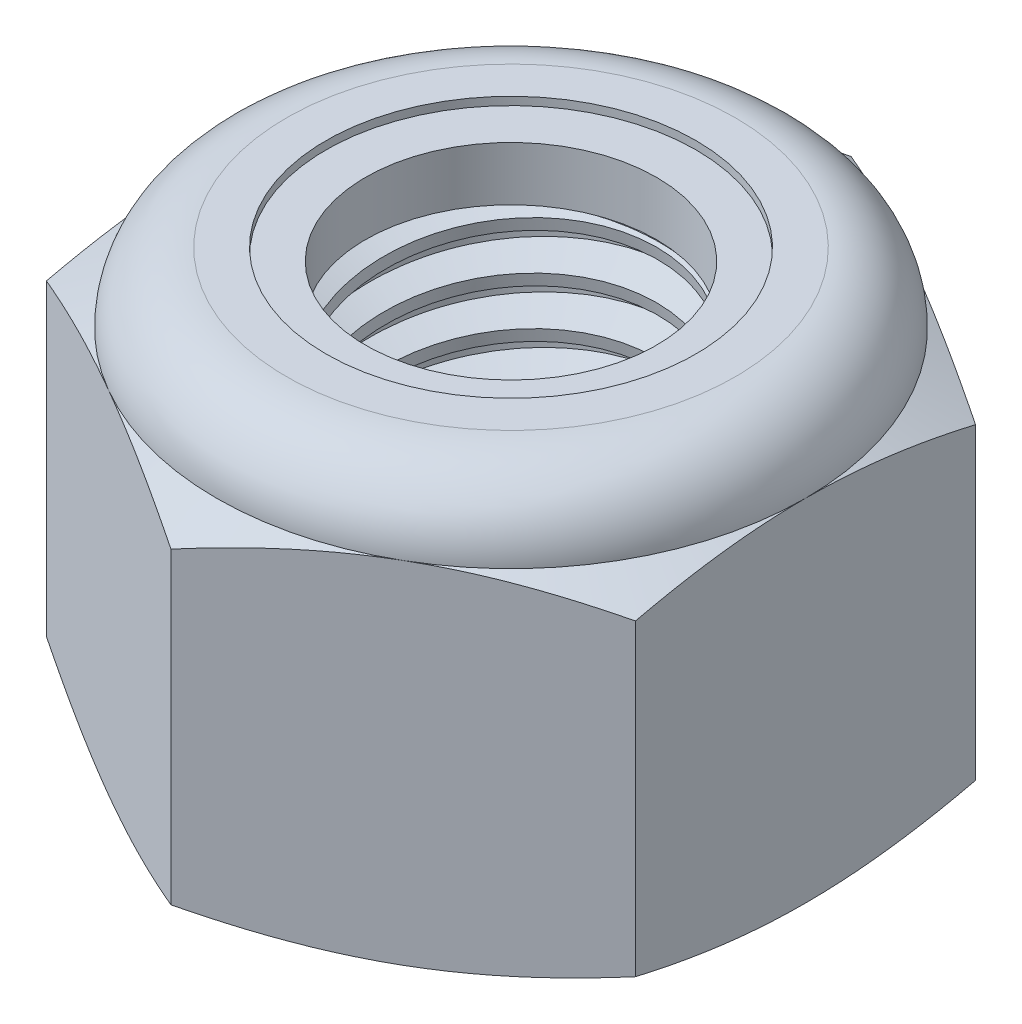
from build123d import *

# Parameters (mm, degrees)
EXTRUDE1_DEPTH      = 7.9375
SKETCH2_W           = 3.175
SKETCH2_H           = 7.9375
LPATTERN1_COUNT     = 9
LPATTERN1_PITCH     = 0.907142857
LPATTERN1_COL_COUNT = 2
LPATTERN1_COL_PITCH = 0.907142857


with BuildPart() as part:
    # Sketch1 → Extrude1 (new body)
    with BuildSketch(Plane(origin=(0, 0, 0), x_dir=(1, 0, 0), z_dir=(0, 1, 0))):
        Polygon((0, 6.415804866), (-5.55625, 3.207902433), (-5.55625, -3.207902433), (0, -6.415804866), (5.55625, -3.207902433), (5.55625, 3.207902433), align=None)
    extrude(amount=EXTRUDE1_DEPTH)

    # Sketch4 → Cut-Revolve2 (revolve, cut)
    with BuildSketch(Plane(origin=(0, 0, 0), x_dir=(0, 0, -1), z_dir=(1, 0, 0))):
        Polygon((0, 7.9375), (3.175, 7.9375), (2.74505598, 7.737013811), (2.74505598, 0.200486189), (3.175, 0), (0, 0), align=None)
    revolve(axis=Axis((0, 7.9375, 0), (0, 1, 0)), mode=Mode.SUBTRACT)


with BuildPart() as body_2:
    # Sketch2 → Revolve1 (revolve)
    with BuildSketch(Plane(origin=(0, 0, 0), x_dir=(0, 0, -1), z_dir=(1, 0, 0))):
        with Locations((1.5875, 3.96875)):
            Rectangle(SKETCH2_W, SKETCH2_H)
    revolve(axis=Axis((0, -3.175, 0), (0, 1, 0)))

    # Sketch3 → Cut-Revolve1 (revolve, cut)
    with BuildSketch(Plane(origin=(0, 0, 0), x_dir=(0, 0, -1), z_dir=(1, 0, 0))):
        Polygon((3.191036172, 7.825246798), (3.303289373, 7.039474388), (2.777128323, 7.250668732), (2.74505598, 7.475175135), align=None)
    cut_revolve1 = revolve(axis=Axis((0, 7.9375, 0.1384314), (0, -0.989949494, -0.141421356)), mode=Mode.SUBTRACT)

    # LPattern1: Cut-Revolve1 ×9
    with Locations(*[(0, -i * LPATTERN1_PITCH, 0) for i in range(1, LPATTERN1_COUNT)]):
        add(cut_revolve1, mode=Mode.SUBTRACT)

    # LPattern1 col: Cut-Revolve1 ×2
    with Locations(*[(0, i * LPATTERN1_COL_PITCH, 0) for i in range(1, LPATTERN1_COL_COUNT)]):
        add(cut_revolve1, mode=Mode.SUBTRACT)


with BuildPart() as part_1:
    add(part.part)

    # Combine1: cut body 2
    add(body_2.part, mode=Mode.SUBTRACT)

    # Sketch5 → Cut-Revolve3 (revolve, cut)
    with BuildSketch(Plane(origin=(0, 0, 0), x_dir=(0, 0, -1), z_dir=(1, 0, 0))):
        with BuildLine():
            Line((0, 0), (5.55625, 0))
            Line((5.55625, 0), (6.415804866, 0.400817017))
            Line((6.415804866, 0.400817017), (6.415804866, 6.213766317))
            Line((6.415804866, 6.213766317), (5.55625, 6.614583333))
            ThreePointArc((5.55625, 6.614583333), (5.168776679, 7.550026679), (4.233333333, 7.9375))
            Line((4.233333333, 7.9375), (4.233333333, 9.2075))
            Line((4.233333333, 9.2075), (7.685804866, 9.2075))
            Line((7.685804866, 9.2075), (7.685804866, -1.27))
            Line((7.685804866, -1.27), (0, -1.27))
            Line((0, -1.27), (0, 0))
        make_face()
    revolve(axis=Axis((0, 0, 0), (0, 1, 0)), mode=Mode.SUBTRACT)

    # Sketch6 → Cut-Revolve4 (revolve, cut)
    with BuildSketch(Plane(origin=(0, 0, 0), x_dir=(0, 0, -1), z_dir=(1, 0, 0))):
        with BuildLine():
            Line((0, 6.614583333), (5.40385, 6.614583333))
            ThreePointArc((5.40385, 6.614583333), (5.061013606, 7.442263606), (4.233333333, 7.7851))
            Line((4.233333333, 7.7851), (3.489194657, 7.7851))
            Line((3.489194657, 7.7851), (3.489194657, 9.2075))
            Line((3.489194657, 9.2075), (0, 9.2075))
            Line((0, 9.2075), (0, 6.614583333))
        make_face()
    revolve(axis=Axis((0, 9.2075, 0), (0, 1, 0)), mode=Mode.SUBTRACT)


with BuildPart() as body_2_2:
    # Sketch7 → Revolve2 (revolve)
    with BuildSketch(Plane(origin=(0, 0, 0), x_dir=(0, 0, -1), z_dir=(1, 0, 0))):
        with BuildLine():
            Line((2.74505598, 6.690783333), (5.324993778, 6.690783333))
            ThreePointArc((5.324993778, 6.690783333), (4.979705237, 7.4148695), (4.233333333, 7.7089))
            Line((4.233333333, 7.7089), (2.74505598, 7.7089))
            Line((2.74505598, 7.7089), (2.74505598, 6.690783333))
        make_face()
    revolve(axis=Axis((0, 6.690783333, 0), (0, 1, 0)))


solid = Compound([part_1.part, body_2_2.part])
